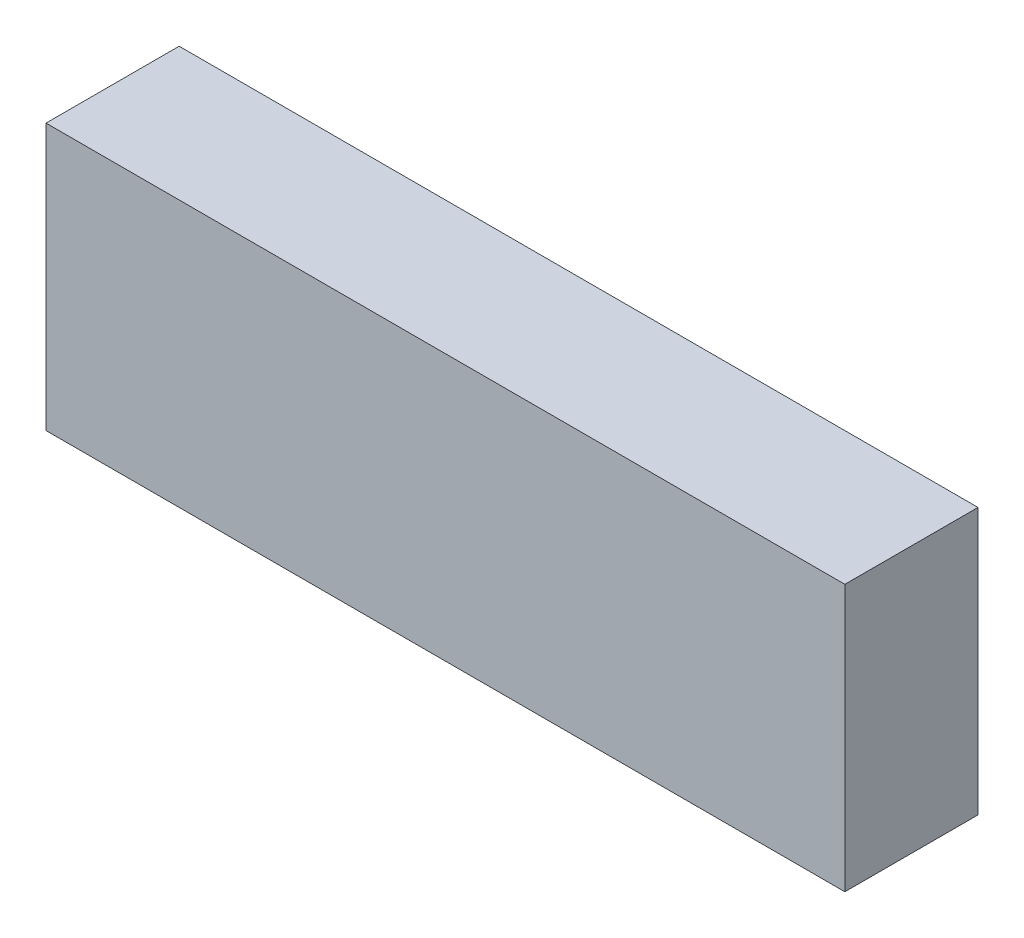
from build123d import *

# Parameters (mm, degrees)
ESQUISSE2_W        = 30
ESQUISSE2_H        = 10
BOSS_EXTRU_2_DEPTH = 2.5


with BuildPart() as part:
    # Esquisse2 → Boss.-Extru.2 (new body, symmetric)
    with BuildSketch(Plane.XY):
        with Locations((-66.65633555, -28.380839861)):
            Rectangle(ESQUISSE2_W, ESQUISSE2_H)
    extrude(amount=BOSS_EXTRU_2_DEPTH, both=True)


solid = part.part
